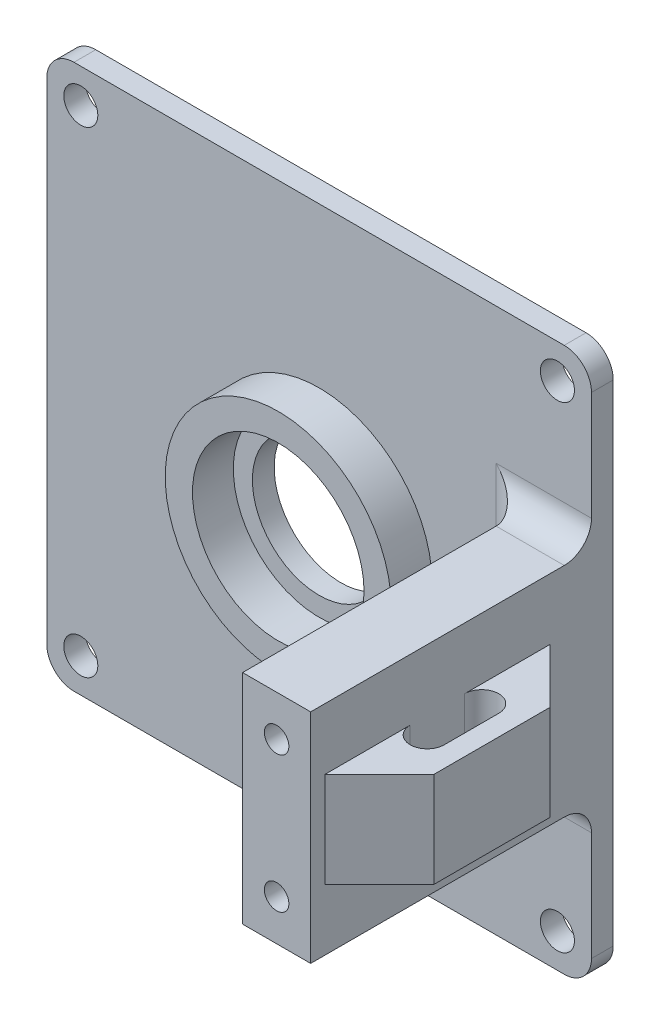
from build123d import *

# Parameters (mm, degrees)
SKETCH1_W           = 50.8
SKETCH1_H           = 50.8
BOSS_EXTRUDE1_DEPTH = 2.032
SKETCH2_R           = 10.541
BOSS_EXTRUDE2_DEPTH = 3.81
SKETCH2_4_R         = 8.001
CUT_EXTRUDE2_DEPTH  = 3.81
SKETCH2_5_R         = 6.223
CUT_EXTRUDE3_DEPTH  = 3.032
SKETCH4_W           = 6.35
SKETCH4_H           = 20.32
BOSS_EXTRUDE3_DEPTH = 26.1874
CUT_EXTRUDE4_START  = 26.1874
SKETCH4_3_R         = 1.143
CUT_EXTRUDE4_DEPTH  = 2.54
CUT_EXTRUDE5_START  = 26.1874
SKETCH4_4_R         = 0.9525
CUT_EXTRUDE5_DEPTH  = 19.05
SKETCH5_R           = 1.5875
CUT_EXTRUDE6_DEPTH  = 3.032
FILLET1_R           = 2.54
FILLET2_R           = 2.54
BOSS_EXTRUDE4_DEPTH = 4.445


with BuildPart() as part:
    # Sketch1 → Boss-Extrude1 (new body)
    with BuildSketch(Plane.XY):
        with Locations((25.4, 25.4)):
            Rectangle(SKETCH1_W, SKETCH1_H)
    extrude(amount=BOSS_EXTRUDE1_DEPTH)

    # Sketch2 → Boss-Extrude2 (add)
    with BuildSketch(Plane.XY.offset(2.032)):
        with Locations((25.4, 25.4)):
            Circle(SKETCH2_R)
    extrude(amount=BOSS_EXTRUDE2_DEPTH)

    # Sketch2_4 → Cut-Extrude2 (cut)
    with BuildSketch(Plane.XY.offset(2.032)):
        with Locations((25.4, 25.4)):
            Circle(SKETCH2_4_R)
    extrude(amount=CUT_EXTRUDE2_DEPTH, mode=Mode.SUBTRACT)

    # Sketch2_5 → Cut-Extrude3 (cut, through all)
    with BuildSketch(Plane.XY.offset(2.032)):
        with Locations((25.4, 25.4)):
            Circle(SKETCH2_5_R)
    extrude(amount=-CUT_EXTRUDE3_DEPTH, mode=Mode.SUBTRACT)

    # Sketch4 → Boss-Extrude3 (add)
    with BuildSketch(Plane.XY.offset(2.032)):
        with Locations((47.625, 25.4)):
            Rectangle(SKETCH4_W, SKETCH4_H)
    extrude(amount=BOSS_EXTRUDE3_DEPTH)

    # Sketch4_3 → Cut-Extrude4 (cut)
    with BuildSketch(Plane.XY.offset(2.032).offset(CUT_EXTRUDE4_START)):
        with Locations((47.625, 31.75)):
            Circle(SKETCH4_3_R)
        with Locations((47.625, 19.05)):
            Circle(SKETCH4_3_R)
    extrude(amount=-CUT_EXTRUDE4_DEPTH, mode=Mode.SUBTRACT)

    # Sketch4_4 → Cut-Extrude5 (cut)
    with BuildSketch(Plane.XY.offset(2.032).offset(CUT_EXTRUDE5_START)):
        with Locations((47.625, 31.75)):
            Circle(SKETCH4_4_R)
        with Locations((47.625, 19.05)):
            Circle(SKETCH4_4_R)
    extrude(amount=-CUT_EXTRUDE5_DEPTH, mode=Mode.SUBTRACT)

    # Sketch5 → Cut-Extrude6 (cut, through all)
    with BuildSketch(Plane.XY.offset(2.032)):
        with Locations((47.625, 47.625)):
            Circle(SKETCH5_R)
        with Locations((47.625, 3.175)):
            Circle(SKETCH5_R)
        with Locations((3.175, 3.175)):
            Circle(SKETCH5_R)
        with Locations((3.175, 47.625)):
            Circle(SKETCH5_R)
    extrude(amount=-CUT_EXTRUDE6_DEPTH, mode=Mode.SUBTRACT)

    # Fillet1
    fillet1_edges = [part.edges().sort_by_distance(p)[0] for p in [
        (47.625, 35.56, 2.032),
        (44.45, 25.4, 2.032),
        (47.625, 15.24, 2.032),
    ]]
    fillet(fillet1_edges, radius=FILLET1_R)

    # Fillet2
    fillet2_edges = [part.edges().sort_by_distance(p)[0] for p in [
        (0, 0, 1.016),
        (0, 50.8, 1.016),
        (50.8, 50.8, 1.016),
        (50.8, 0, 1.016),
    ]]
    fillet(fillet2_edges, radius=FILLET2_R)

    # Sketch6 → Boss-Extrude4 (add, symmetric)
    with BuildSketch(Plane(origin=(0, 25.4, 0), x_dir=(-1, 0, 0), z_dir=(0, -1, 0))):
        with BuildLine():
            ThreePointArc((-53.975, -13.8557), (-52.3875, -12.2682), (-50.8, -13.8557))
            Line((-50.8, -13.8557), (-50.8, -10.9982))
            Line((-50.8, -10.9982), (-50.8, -5.9182))
            Line((-50.8, -5.9182), (-55.88, -10.9982))
            Line((-55.88, -10.9982), (-55.88, -21.7932))
            Line((-55.88, -21.7932), (-50.8, -26.8732))
            Line((-50.8, -26.8732), (-50.8, -21.7932))
            Line((-50.8, -21.7932), (-50.8, -18.9357))
            ThreePointArc((-50.8, -18.9357), (-52.3875, -20.5232), (-53.975, -18.9357))
            Line((-53.975, -18.9357), (-53.975, -13.8557))
        make_face()
    extrude(amount=BOSS_EXTRUDE4_DEPTH, both=True)


solid = part.part
